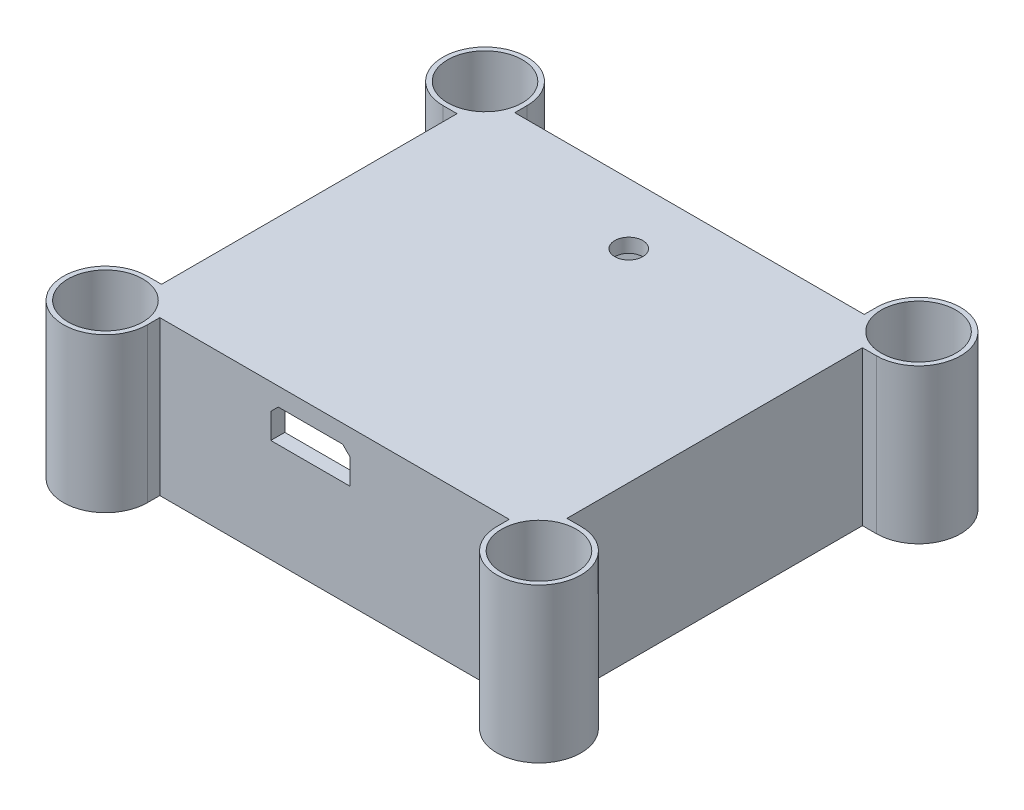
from build123d import *

# Parameters (mm, degrees)
SKETCH1_W           = 40.4
SKETCH1_H           = 35
SKETCH1_R           = 2
BOSS_EXTRUDE1_DEPTH = 15
SKETCH2_R           = 2
BOSS_EXTRUDE2_DEPTH = 1.5
SKETCH3_R           = 4
CUT_EXTRUDE1_DEPTH  = 15
SKETCH4_W           = 13
SKETCH4_H           = 3.8
SKETCH4_W_2         = 3
SKETCH4_H_2         = 3
SKETCH4_W_3         = 18.15
SKETCH4_W_4         = 2.5
SKETCH4_H_3         = 2
BOSS_EXTRUDE3_DEPTH = 1.1
SKETCH5_W           = 3
SKETCH5_H           = 3.5
SKETCH5_W_2         = 2.5
SKETCH5_H_2         = 2.5
SKETCH5_H_3         = 4.3
BOSS_EXTRUDE4_DEPTH = 1
CHAMFER1_SIZE       = 0.5
CUT_EXTRUDE2_REACH  = 9.318
SKETCH6_W           = 8.5
SKETCH6_H           = 3.5
CHAMFER2_SIZE       = 0.8
FILLET1_R           = 2
CUT_EXTRUDE3_REACH  = 3.5
SKETCH7_R           = 1.5


with BuildPart() as part:
    # Sketch1 → Boss-Extrude1 (new body)
    with BuildSketch(Plane(origin=(0, 0, 0), x_dir=(1, 0, 0), z_dir=(0, 1, 0))):
        with BuildLine():
            Line((-21.7, 15.817500063), (-21.7, -15.817500063))
            Line((-21.7, -15.817500063), (-23.204723756, -15.817500063))
            ThreePointArc((-23.204723756, -15.817500063), (-26.386704272, -23.499480579), (-18.704723756, -20.317500063))
            Line((-18.704723756, -20.317500063), (-18.704723756, -19))
            Line((-18.704723756, -19), (18.704723756, -19))
            Line((18.704723756, -19), (18.704723756, -20.317500063))
            ThreePointArc((18.704723756, -20.317500063), (26.386704272, -23.499480579), (23.204723756, -15.817500063))
            Line((23.204723756, -15.817500063), (21.7, -15.817500063))
            Line((21.7, -15.817500063), (21.7, 15.817500063))
            Line((21.7, 15.817500063), (23.204723756, 15.817500063))
            ThreePointArc((23.204723756, 15.817500063), (26.386704272, 23.499480579), (18.704723756, 20.317500063))
            Line((18.704723756, 20.317500063), (18.704723756, 19))
            Line((18.704723756, 19), (-18.704723756, 19))
            Line((-18.704723756, 19), (-18.704723756, 20.317500063))
            ThreePointArc((-18.704723756, 20.317500063), (-26.386704272, 23.499480579), (-23.204723756, 15.817500063))
            Line((-23.204723756, 15.817500063), (-21.7, 15.817500063))
        make_face()
        Rectangle(SKETCH1_W, SKETCH1_H, mode=Mode.SUBTRACT)
        with Locations((-23.204723756, 20.317500063)):
            Circle(SKETCH1_R, mode=Mode.SUBTRACT)
        with Locations((-23.204723756, -20.317500063)):
            Circle(SKETCH1_R, mode=Mode.SUBTRACT)
        with Locations((23.204723756, 20.317500063)):
            Circle(SKETCH1_R, mode=Mode.SUBTRACT)
        with Locations((23.204723756, -20.317500063)):
            Circle(SKETCH1_R, mode=Mode.SUBTRACT)
    extrude(amount=BOSS_EXTRUDE1_DEPTH)

    # Sketch2 → Boss-Extrude2 (add)
    with BuildSketch(Plane(origin=(0, 15, 0), x_dir=(1, 0, 0), z_dir=(0, 1, 0))):
        with BuildLine():
            Line((-21.7, 15.817500063), (-21.7, -15.817500063))
            Line((-21.7, -15.817500063), (-23.204723756, -15.817500063))
            ThreePointArc((-23.204723756, -15.817500063), (-26.386704272, -23.499480579), (-18.704723756, -20.317500063))
            Line((-18.704723756, -20.317500063), (-18.704723756, -19))
            Line((-18.704723756, -19), (18.704723756, -19))
            Line((18.704723756, -19), (18.704723756, -20.317500063))
            ThreePointArc((18.704723756, -20.317500063), (26.386704272, -23.499480579), (23.204723756, -15.817500063))
            Line((23.204723756, -15.817500063), (21.7, -15.817500063))
            Line((21.7, -15.817500063), (21.7, 15.817500063))
            Line((21.7, 15.817500063), (23.204723756, 15.817500063))
            ThreePointArc((23.204723756, 15.817500063), (26.386704272, 23.499480579), (18.704723756, 20.317500063))
            Line((18.704723756, 20.317500063), (18.704723756, 19))
            Line((18.704723756, 19), (-18.704723756, 19))
            Line((-18.704723756, 19), (-18.704723756, 20.317500063))
            ThreePointArc((-18.704723756, 20.317500063), (-26.386704272, 23.499480579), (-23.204723756, 15.817500063))
            Line((-23.204723756, 15.817500063), (-21.7, 15.817500063))
        make_face()
        with Locations((23.204723756, -20.317500063)):
            Circle(SKETCH2_R, mode=Mode.SUBTRACT)
        with Locations((23.204723756, 20.317500063)):
            Circle(SKETCH2_R, mode=Mode.SUBTRACT)
        with Locations((-23.204723756, 20.317500063)):
            Circle(SKETCH2_R, mode=Mode.SUBTRACT)
        with Locations((-23.204723756, -20.317500063)):
            Circle(SKETCH2_R, mode=Mode.SUBTRACT)
    extrude(amount=BOSS_EXTRUDE2_DEPTH)

    # Sketch3 → Cut-Extrude1 (cut)
    with BuildSketch(Plane(origin=(0, 16.5, 0), x_dir=(1, 0, 0), z_dir=(0, 1, 0))):
        with Locations((-23.204723756, -20.317500063)):
            Circle(SKETCH3_R)
        with Locations((-23.204723756, 20.317500063)):
            Circle(SKETCH3_R)
        with Locations((23.204723756, 20.317500063)):
            Circle(SKETCH3_R)
        with Locations((23.204723756, -20.317500063)):
            Circle(SKETCH3_R)
    extrude(amount=-CUT_EXTRUDE1_DEPTH, mode=Mode.SUBTRACT)

    # Sketch4 → Boss-Extrude3 (add)
    with BuildSketch(Plane.XZ.offset(-15)):
        with Locations((-13.7, 15.6)):
            Rectangle(SKETCH4_W, SKETCH4_H)
        with Locations((-18.7, -16)):
            Rectangle(SKETCH4_W_2, SKETCH4_H_2)
        with Locations((11.125, 15.6)):
            Rectangle(SKETCH4_W_3, SKETCH4_H)
        with Locations((13.2, -16.5)):
            Rectangle(SKETCH4_W_4, SKETCH4_H_3)
    extrude(amount=BOSS_EXTRUDE3_DEPTH)

    # Sketch5 → Boss-Extrude4 (add)
    with BuildSketch(Plane.XZ.offset(-13.9)):
        with Locations((-18.7, -15.75)):
            Rectangle(SKETCH5_W, SKETCH5_H)
        with Locations((13.2, -16.25)):
            Rectangle(SKETCH5_W_2, SKETCH5_H_2)
        with Locations((-13.7, 15.35)):
            Rectangle(SKETCH5_W, SKETCH5_H_3)
        with Locations((11.125, 15.35)):
            Rectangle(SKETCH5_W, SKETCH5_H_3)
    extrude(amount=BOSS_EXTRUDE4_DEPTH)

    # Chamfer1
    chamfer1_edges = [part.edges().sort_by_distance(p)[0] for p in [
        (-18.7, 12.9, -14),
        (13.2, 12.9, -15),
    ]]
    chamfer(chamfer1_edges, length=CHAMFER1_SIZE)

    # Sketch6 → Cut-Extrude2 (cut, up to next)
    with BuildSketch(Plane(origin=(0, 0, 17.5), x_dir=(-1, 0, 0), z_dir=(0, 0, -1)), mode=Mode.PRIVATE) as cut_extrude2_sk1:
        with Locations((2.575, 12.8)):
            Rectangle(SKETCH6_W, SKETCH6_H)
    cut_extrude2_tool1 = extrude(cut_extrude2_sk1.sketch, amount=-CUT_EXTRUDE2_REACH, mode=Mode.PRIVATE) & part.part
    add(cut_extrude2_tool1.solids().sort_by_distance((-2.575, 12.8, 17.5))[0], mode=Mode.SUBTRACT)

    # Chamfer2
    chamfer2_edges = [part.edges().sort_by_distance(p)[0] for p in [
        (-6.825, 14.55, 18.25),
        (1.675, 14.55, 18.25),
    ]]
    chamfer(chamfer2_edges, length=CHAMFER2_SIZE)

    # Fillet1
    fillet1_edges = [part.edges().sort_by_distance(p)[0] for p in [
        (-20.2, 6.95, 17.5),
        (20.2, 6.95, 17.5),
        (-20.2, 6.45, -17.5),
        (20.2, 7.5, -17.5),
    ]]
    fillet(fillet1_edges, radius=FILLET1_R)

    # Sketch7 → Cut-Extrude3 (cut, up to next)
    with BuildSketch(Plane.XZ.offset(-15), mode=Mode.PRIVATE) as cut_extrude3_sk1:
        with Locations((0, -12.5)):
            Circle(SKETCH7_R)
    cut_extrude3_tool1 = extrude(cut_extrude3_sk1.sketch, amount=-CUT_EXTRUDE3_REACH, mode=Mode.PRIVATE) & part.part
    add(cut_extrude3_tool1.solids().sort_by_distance((0, 15, -12.5))[0], mode=Mode.SUBTRACT)


solid = part.part
